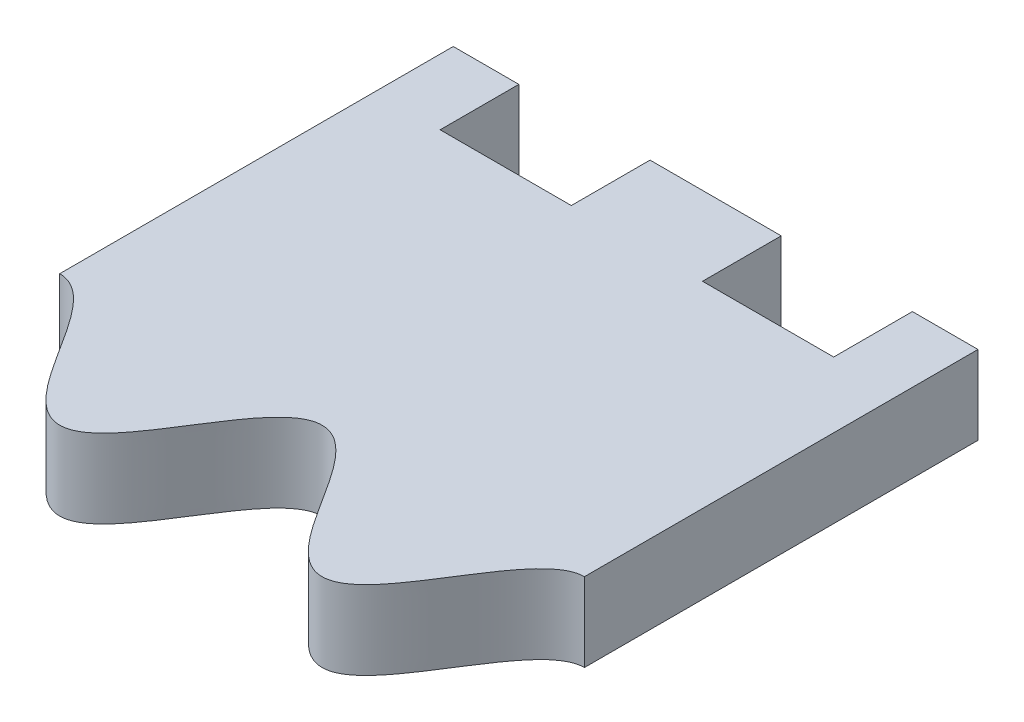
from build123d import *

# Parameters (mm, degrees)
SKETCH1_W               = 20
SKETCH1_H               = 20
BOSS_EXTRUDE1_DEPTH     = 3
CUT_EXTRUDE1_DEPTH      = 1
CUT_EXTRUDE1_DEPTH_BACK = 4
CUT_EXTRUDE2_START      = -4.0000001
SKETCH3_W               = 5
SKETCH3_H               = 3
CUT_EXTRUDE2_DEPTH      = 5.0000002


with BuildPart() as part:
    # Sketch1 → Boss-Extrude1 (new body)
    with BuildSketch(Plane(origin=(0, 0, 0), x_dir=(1, 0, 0), z_dir=(0, 1, 0))):
        Rectangle(SKETCH1_W, SKETCH1_H)
    extrude(amount=BOSS_EXTRUDE1_DEPTH)

    # Sketch2 → Cut-Extrude1 (cut, two sides)
    with BuildSketch(Plane(origin=(0, 3, 0), x_dir=(1, 0, 0), z_dir=(0, 1, 0))) as cut_extrude1_sk:
        with BuildLine():
            Line((10, -5), (10, -10))
            Line((10, -10), (-10, -10))
            Line((-10, -10), (-10, -5))
            add(Edge.make_bspline(
                [(-10, -5), (-9.990820014, -5), (-9.972446358, -5.000312583), (-9.939387471, -5.001719207), (-9.891969519, -5.005454846), (-9.835922238, -5.012412312), (-9.773033767, -5.024336094), (-9.698898541, -5.043219482), (-9.616042774, -5.071043877), (-9.515396925, -5.112824909), (-9.387330606, -5.178878831), (-9.23713056, -5.27635471), (-9.069968341, -5.409823327), (-8.904575648, -5.56508434), (-8.748961229, -5.730063259), (-8.601307785, -5.902136841), (-8.460077009, -6.079495517), (-8.324040002, -6.260844972), (-8.182655276, -6.458534299), (-8.035907031, -6.672418147), (-7.883481419, -6.902191288), (-7.724773455, -7.147377745), (-7.528350495, -7.455132252), (-7.293570647, -7.825001596), (-7.034646201, -8.226061179), (-6.743001489, -8.652533353), (-6.452756272, -9.038649676), (-6.159779288, -9.379451937), (-5.85167298, -9.669361598), (-5.520999117, -9.889512746), (-5.1671847, -10.010779605), (-4.816698271, -10.008204715), (-4.463198002, -9.88148029), (-4.132459412, -9.656303518), (-3.825186178, -9.363374601), (-3.53356605, -9.021407523), (-3.244609582, -8.635018563), (-2.954198132, -8.209090349), (-2.656866985, -7.747954266), (-2.345814717, -7.256271996), (-2.048553648, -6.795091334), (-1.758278976, -6.369070745), (-1.469541055, -5.982521438), (-1.178223955, -5.64030017), (-0.871397136, -5.346926797), (-0.541242947, -5.120949541), (-0.188339321, -4.992783545), (0.16212755, -4.988339301), (0.516516059, -5.108123798), (0.8477895, -5.327441362), (1.156337611, -5.616901018), (1.449649401, -5.957422311), (1.74008086, -6.343405241), (2.031929598, -6.769728753), (2.409645941, -7.354878505), (2.78090923, -7.94523233), (3.145749907, -8.501293993), (3.523293189, -9.008647271), (3.816859253, -9.354615385), (4.126025436, -9.651259116), (4.458963509, -9.879556068), (4.814535153, -10.008097061), (5.166519062, -10.011015315), (5.520996053, -9.889508756), (5.851675295, -9.66936442), (6.159777431, -9.379449939), (6.452757598, -9.03865066), (6.743000269, -8.652533063), (7.034647701, -8.226060806), (7.33317531, -7.763653858), (7.606423384, -7.331721448), (7.843119223, -6.963037632), (8.035904931, -6.672419587), (8.182657184, -6.458533403), (8.324037842, -6.260845485), (8.46008018, -6.079495251), (8.601302819, -5.902136908), (8.748969193, -5.730063373), (8.904563093, -5.565084029), (9.069986411, -5.409823833), (9.237102577, -5.276353888), (9.405693689, -5.166993054), (9.554516523, -5.093477505), (9.677662689, -5.048613087), (9.773048533, -5.024336542), (9.835921683, -5.012412295), (9.891968482, -5.005454815), (9.939387047, -5.001719194), (9.972446314, -5.000312581), (9.990820016, -5), (10, -5)],
                knots=[0.078815497, 0.078815497, 0.078815497, 0.078815497, 0.078815497, 0.080069856, 0.081324215, 0.082578574, 0.083832933, 0.086341651, 0.088850368, 0.091359086, 0.093867804, 0.09888524, 0.105408028, 0.111930817, 0.118453605, 0.124976394, 0.131499182, 0.138021971, 0.144544759, 0.151067548, 0.159472006, 0.167876463, 0.176280921, 0.184685379, 0.201494294, 0.21830321, 0.231223727, 0.244144245, 0.257064762, 0.26998528, 0.279768525, 0.289551769, 0.299506241, 0.309460713, 0.32238219, 0.335303668, 0.348225145, 0.361146623, 0.377889241, 0.394631859, 0.411374477, 0.428117095, 0.441038583, 0.453960071, 0.466881559, 0.479803047, 0.489757501, 0.499711955, 0.509495208, 0.519278461, 0.532198992, 0.545119522, 0.558040052, 0.570960582, 0.587769476, 0.604578369, 0.638196155, 0.651241751, 0.664287347, 0.677332943, 0.690378539, 0.700413385, 0.710448231, 0.720231475, 0.73001472, 0.742935238, 0.755855755, 0.768776273, 0.78169679, 0.798505706, 0.815314621, 0.832123537, 0.840527994, 0.848932452, 0.855455241, 0.861978029, 0.868500818, 0.875023606, 0.881546395, 0.888069183, 0.894591972, 0.90111476, 0.906132196, 0.911149632, 0.913658349, 0.916167067, 0.917421426, 0.918675785, 0.919930144, 0.921184503, 0.921184503, 0.921184503, 0.921184503, 0.921184503], degree=4))
        make_face()
    extrude(amount=CUT_EXTRUDE1_DEPTH, mode=Mode.SUBTRACT)
    extrude(cut_extrude1_sk.sketch, amount=-CUT_EXTRUDE1_DEPTH_BACK, mode=Mode.SUBTRACT)

    # Sketch3 → Cut-Extrude2 (cut)
    with BuildSketch(Plane(origin=(0, 3, 0), x_dir=(1, 0, 0), z_dir=(0, 1, 0)).offset(CUT_EXTRUDE2_START)):
        with Locations((-5, 8.5)):
            Rectangle(SKETCH3_W, SKETCH3_H)
    cut_extrude2 = extrude(amount=CUT_EXTRUDE2_DEPTH, mode=Mode.SUBTRACT)

    # Mirror1: Cut-Extrude2 across plane
    add(cut_extrude2.mirror(Plane(origin=(0, 0, 0), x_dir=(0, 0, 1), z_dir=(1, 0, 0))), mode=Mode.SUBTRACT)


solid = part.part
